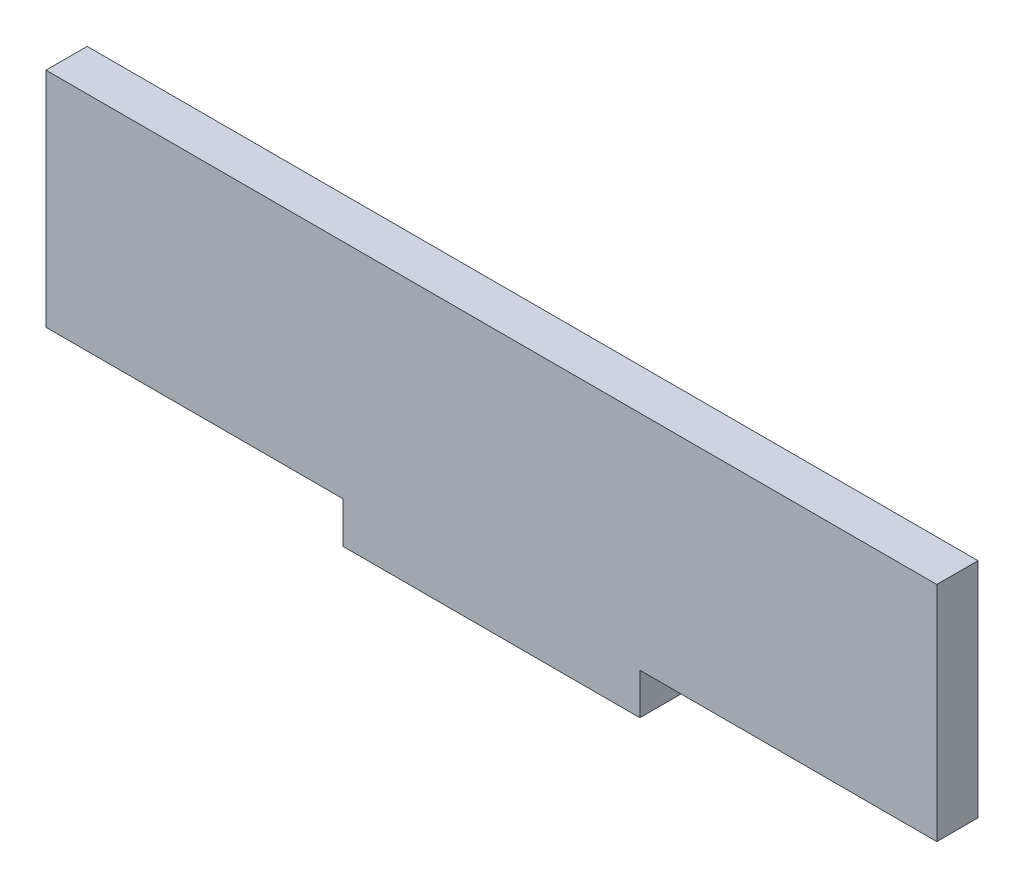
from build123d import *

# Parameters (mm, degrees)
BOSS_EXTRUDE1_DEPTH = 4.699


with BuildPart() as part:
    # Sketch1 → Boss-Extrude1 (new body)
    with BuildSketch(Plane.XY):
        Polygon((67.733333333, 0), (101.6, 0), (101.6, 25.4), (0, 25.4), (0, 0), (33.866666667, 0), (33.866666667, -4.699), (67.733333333, -4.699), align=None)
    extrude(amount=BOSS_EXTRUDE1_DEPTH)


solid = part.part
